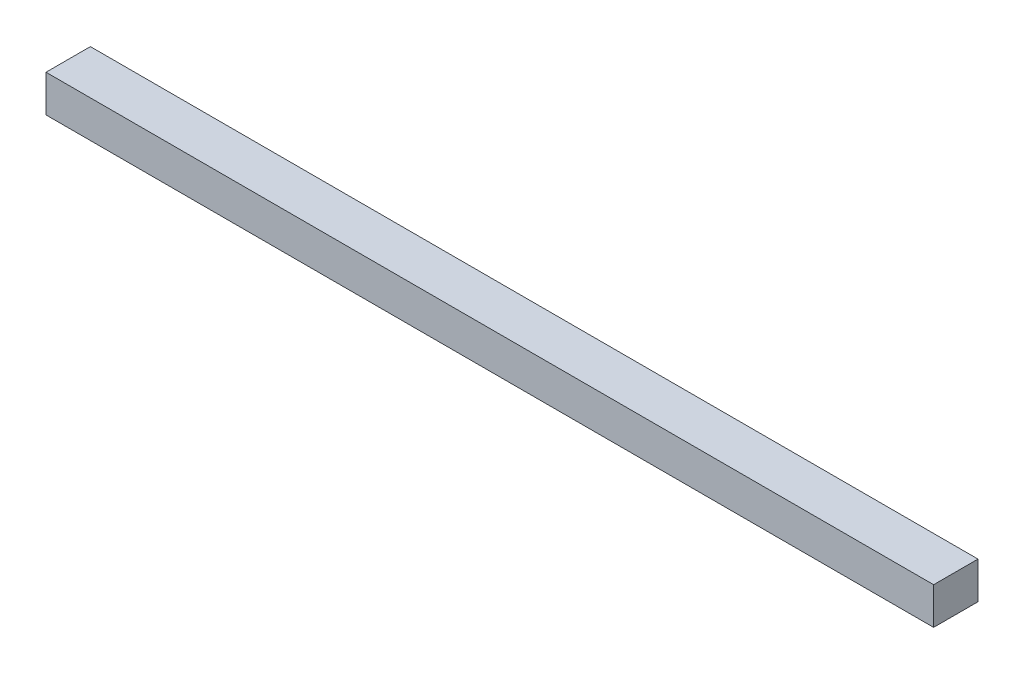
from build123d import *

# Parameters (mm, degrees)
SKETCH_2_W      = 30
SKETCH_2_H      = 25
EXTRUDE_1_DEPTH = 600


with BuildPart() as part:
    # Эскиз2 → Бобышка-Вытянуть1 (new body)
    with BuildSketch(Plane(origin=(0, 0, 0), x_dir=(0, 0, -1), z_dir=(1, 0, 0))):
        Rectangle(SKETCH_2_W, SKETCH_2_H)
    extrude(amount=EXTRUDE_1_DEPTH)


solid = part.part
